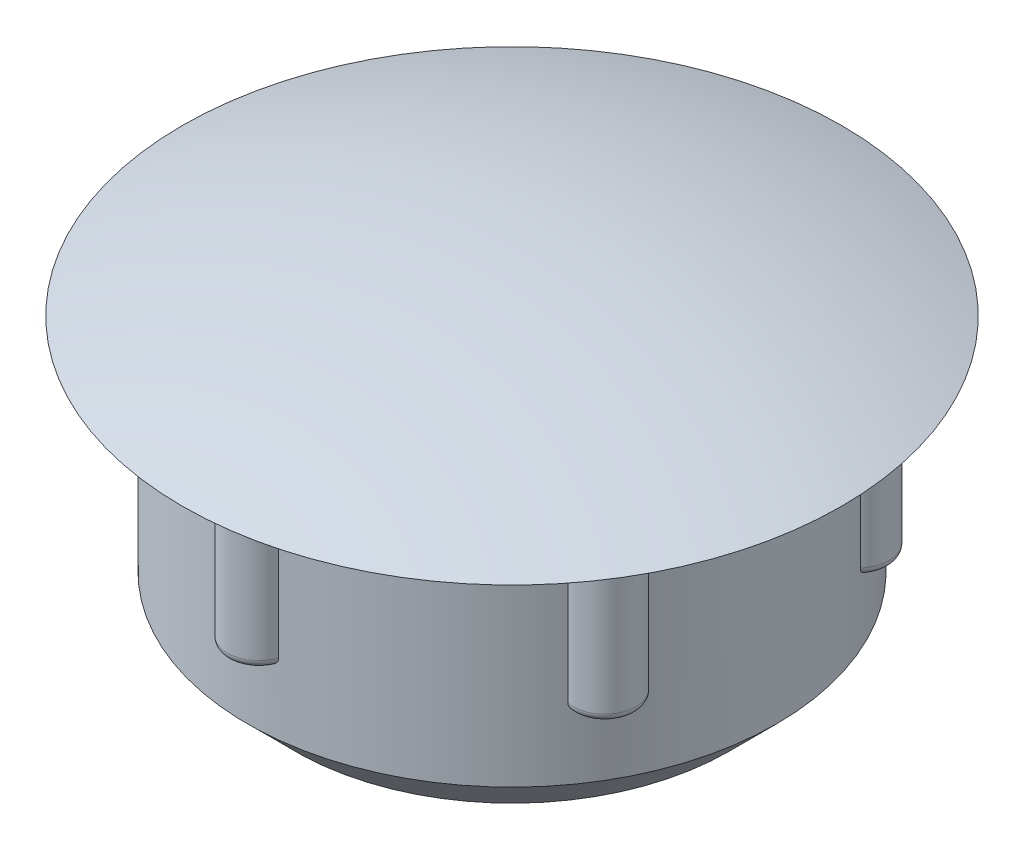
from build123d import *

# Parameters (mm, degrees)
EXTRUDE_1_DEPTH          = 4
PATTERN_CIRCULAR_1_COUNT = 6
FILLET_1_R               = 0.2


with BuildPart() as part:
    # Эскиз1 → Повернуть1 (revolve)
    with BuildSketch(Plane.XY):
        with BuildLine():
            Line((8.35, 0), (6.7, 0))
            Line((6.7, 0), (6.7, -5.6))
            Line((6.7, -5.6), (5.5, -6.8))
            Line((5.5, -6.8), (5.5, -0.5))
            Line((5.5, -0.5), (0, -0.5))
            Line((0, -0.5), (0, 1.5))
            ThreePointArc((0, 1.5), (4.241830383, 1.122022467), (8.35, 0))
        make_face()
    revolve(axis=Axis((0, -0.5, 0), (0, -1, 0)))

    # Эскиз2 → Бобышка-Вытянуть1 (add)
    with BuildSketch(Plane.XZ):
        with BuildLine():
            ThreePointArc((-0.75, 6.657890056), (0, 7.2), (0.75, 6.657890056))
            ThreePointArc((0.75, 6.657890056), (0, 6.7), (-0.75, 6.657890056))
        make_face()
    extrude_1 = extrude(amount=EXTRUDE_1_DEPTH)

    # Круговой массив1: Бобышка-Вытянуть1 ×6 about axis
    pattern_circular_1_axis = Axis((0, 0, 0), (0, 1, 0))
    for i in range(1, PATTERN_CIRCULAR_1_COUNT):
        add(extrude_1.rotate(pattern_circular_1_axis, i * 360 / PATTERN_CIRCULAR_1_COUNT))

    # Скругление1
    fillet_1_edges = [part.edges().sort_by_distance(p)[0] for p in [
        (0, -4, 7.2),
        (6.235382907, -4, 3.6),
        (6.235382907, -4, -3.6),
        (0, -4, -7.2),
        (-6.235382907, -4, -3.6),
        (-6.235382907, -4, 3.6),
    ]]
    fillet(fillet_1_edges, radius=FILLET_1_R)


solid = part.part
